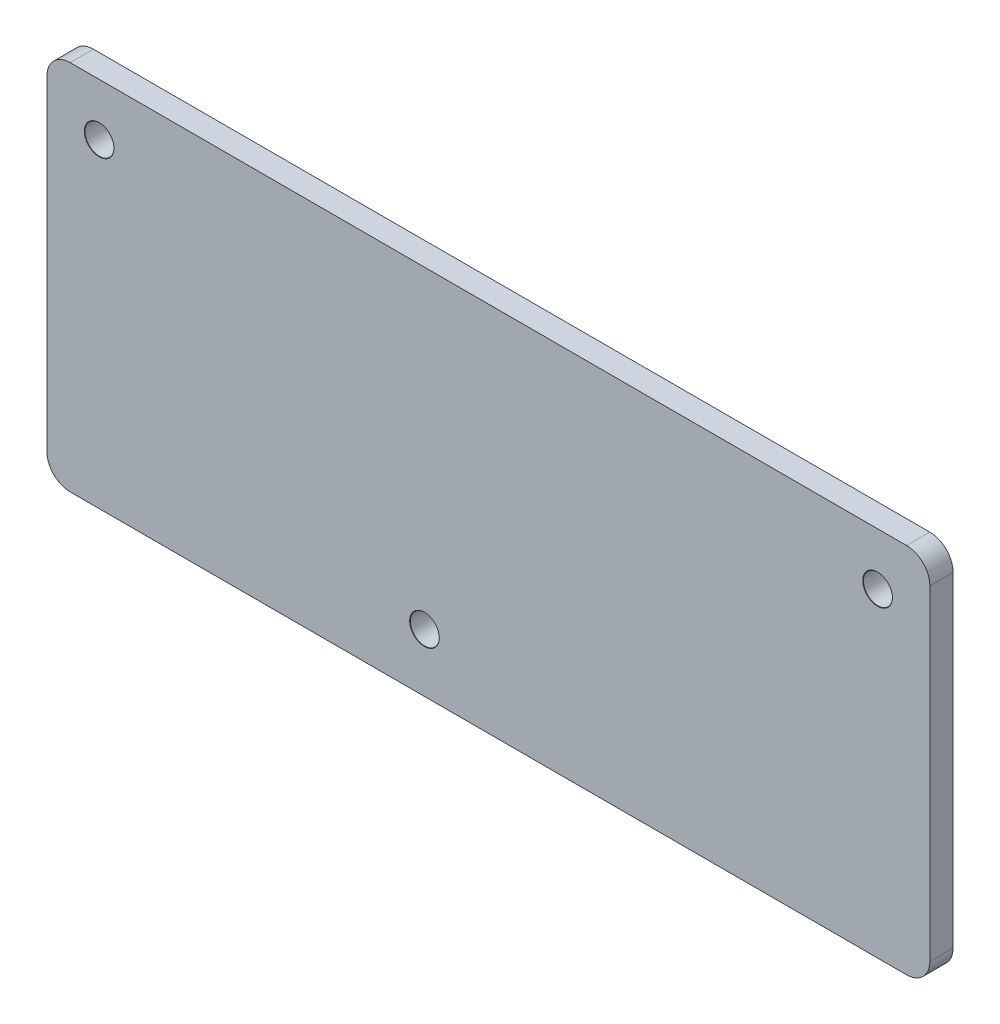
from build123d import *

# Parameters (mm, degrees)
BOSS_EXTRUDE1_DEPTH               = 2
TAP_DRILL_FOR_M3_TAP1_D           = 2.5
TAP_DRILL_FOR_M3_TAP1_CSINK_D     = 2.55
TAP_DRILL_FOR_M3_TAP1_CSINK_ANGLE = 90


with BuildPart() as part:
    # Model → Boss-Extrude1 (new body)
    with BuildSketch(Plane.XY):
        with BuildLine():
            Line((-38, 14), (-38, -14))
            ThreePointArc((-38, -14), (-37.414213562, -15.414213562), (-36, -16))
            Line((-36, -16), (36, -16))
            ThreePointArc((36, -16), (37.414213562, -15.414213562), (38, -14))
            Line((38, -14), (38, 14))
            ThreePointArc((38, 14), (37.414213562, 15.414213562), (36, 16))
            Line((36, 16), (-36, 16))
            ThreePointArc((-36, 16), (-37.414213562, 15.414213562), (-38, 14))
        make_face()
    extrude(amount=BOSS_EXTRUDE1_DEPTH)

    # Tap Drill for M3 Tap1 (through all)
    with Locations(Plane.XY.offset(2)):
        with Locations((-33.5, 11.5), (-5.5, -11), (33.5, 11.5)):
            CounterSinkHole(TAP_DRILL_FOR_M3_TAP1_D / 2, TAP_DRILL_FOR_M3_TAP1_CSINK_D / 2, counter_sink_angle=TAP_DRILL_FOR_M3_TAP1_CSINK_ANGLE)


solid = part.part
